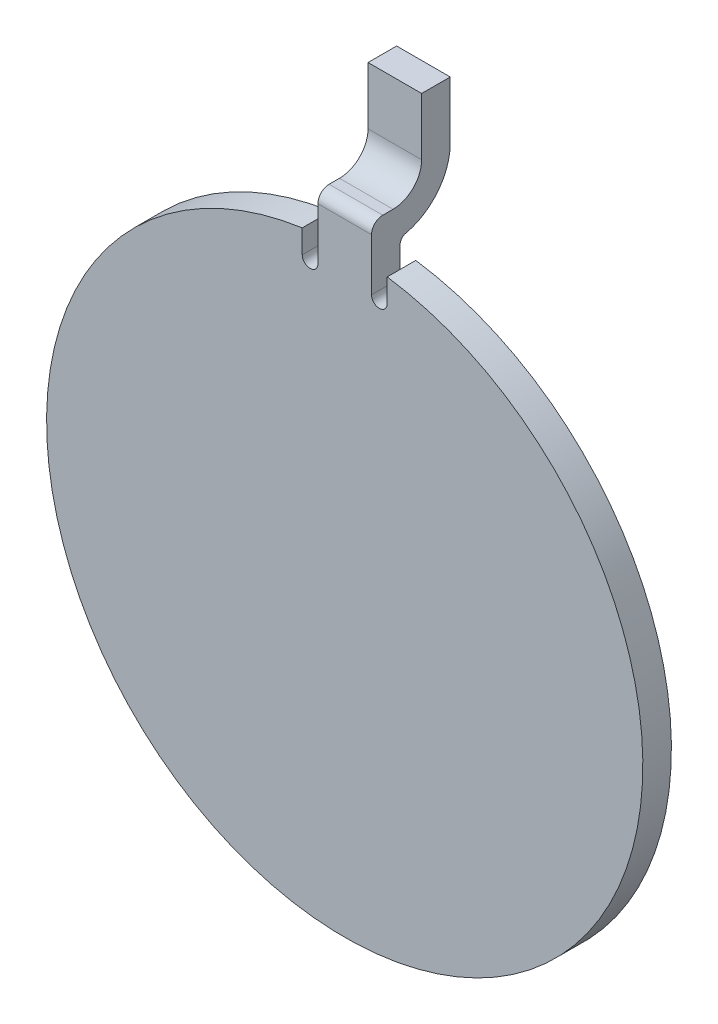
from build123d import *

# Parameters (mm, degrees)
BOSS_EXTRUDE1_DEPTH = 0.508
EXTRUDE_THIN1_DEPTH = 0.953015
FILLET1_R           = 0.127
FILLET3_R           = 0.2
CUT_EXTRUDE1_DEPTH  = 1.508


with BuildPart() as part:
    # Sketch2 → Boss-Extrude1 (new body)
    with BuildSketch(Plane(origin=(0, 0, 11.176), x_dir=(-1, 0, 0), z_dir=(0, 0, -1))):
        with BuildLine():
            Line((0.476507589, 37.02763682), (0.476507589, 37.705519621))
            Line((0.476507589, 37.705519621), (-0.476507589, 37.705519621))
            Line((-0.476507589, 37.705519621), (-0.476507589, 37.02763682))
            ThreePointArc((-0.476507589, 37.02763682), (0, 26.45089537), (0.476507589, 37.02763682))
        make_face()
    extrude(amount=BOSS_EXTRUDE1_DEPTH)

    # Sketch3 → Extrude-Thin1 (add)
    with BuildSketch(Plane.ZY.offset(0.476507589)):
        with BuildLine():
            Line((11.176, 37.705519621), (10.792876614, 37.705519621))
            ThreePointArc((10.792876614, 37.705519621), (10.433666369, 37.854309376), (10.284876614, 38.213519621))
            Line((10.284876614, 38.213519621), (10.284876614, 39.233944616))
            Line((10.284876614, 39.233944616), (9.776876614, 39.233944616))
            Line((9.776876614, 39.233944616), (9.776876614, 38.213519621))
            ThreePointArc((9.776876614, 38.213519621), (10.074456124, 37.495099131), (10.792876614, 37.197519621))
            Line((10.792876614, 37.197519621), (11.176, 37.197519621))
            Line((11.176, 37.197519621), (11.176, 37.705519621))
        make_face()
    extrude(amount=-EXTRUDE_THIN1_DEPTH)

    # Fillet1
    fillet1_edges = [part.edges().sort_by_distance(p)[0] for p in [
        (-4.5e-08, 37.205223121, 10.668),
    ]]
    fillet(fillet1_edges, radius=FILLET1_R)

    # Fillet3
    fillet3_edges = [part.edges().sort_by_distance(p)[0] for p in [
        (0, 37.705519621, 11.176),
    ]]
    fillet(fillet3_edges, radius=FILLET3_R)

    # Sketch4 → Cut-Extrude1 (cut, through all)
    with BuildSketch(Plane(origin=(0, 0, 10.668), x_dir=(-1, 0, 0), z_dir=(0, 0, -1))):
        with BuildLine():
            Line((0.755096408, 37.083870595), (0.755096408, 36.580152381))
            ThreePointArc((0.755096408, 36.580152381), (0.615801999, 36.440857972), (0.476507589, 36.580152381))
            Line((0.476507589, 36.580152381), (0.476507589, 37.083870595))
            ThreePointArc((0.476507589, 37.083870595), (0.615801999, 37.223165004), (0.755096408, 37.083870595))
        make_face()
        with BuildLine():
            Line((-0.755096408, 37.083870595), (-0.755096408, 36.580152381))
            ThreePointArc((-0.755096408, 36.580152381), (-0.615801999, 36.440857972), (-0.476507589, 36.580152381))
            Line((-0.476507589, 36.580152381), (-0.476507589, 37.083870595))
            ThreePointArc((-0.476507589, 37.083870595), (-0.615801999, 37.223165004), (-0.755096408, 37.083870595))
        make_face()
    extrude(amount=-CUT_EXTRUDE1_DEPTH, mode=Mode.SUBTRACT)


solid = part.part
